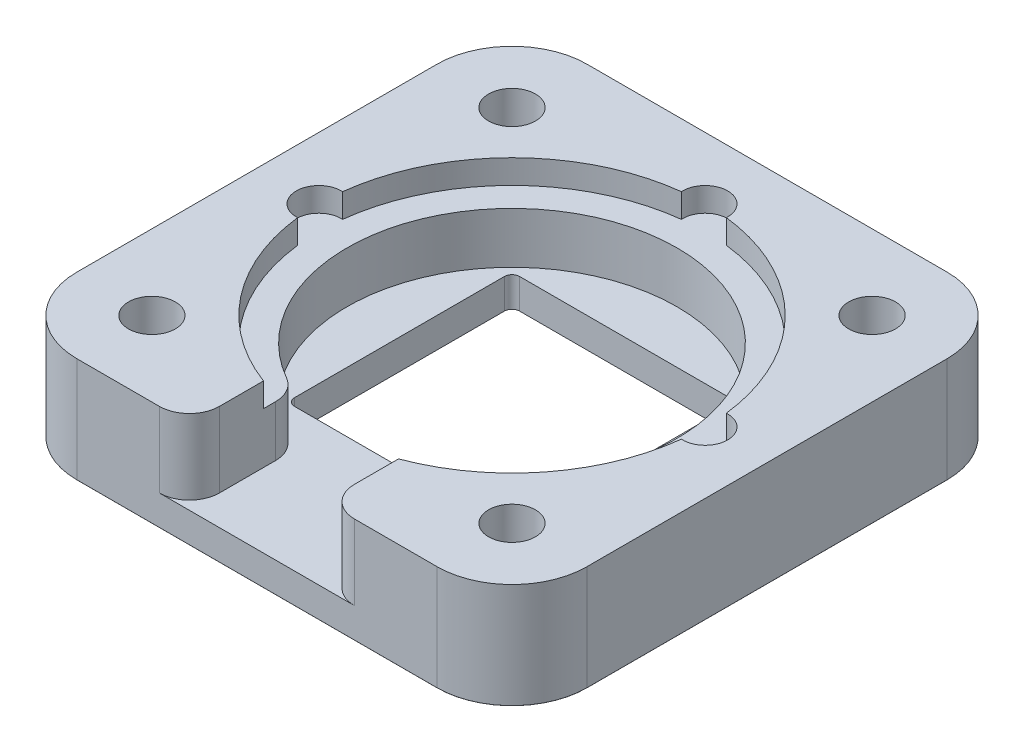
from build123d import *

# Parameters (mm, degrees)
SKETCH1_W           = 34
SKETCH1_H           = 34
BOSS_EXTRUDE1_DEPTH = 7
SKETCH2_R           = 11
CUT_EXTRUDE1_DEPTH  = 5
SKETCH3_R           = 1.5621
CUT_EXTRUDE2_DEPTH  = 8
SKETCH4_W           = 9
SKETCH4_H           = 12.899537492
CUT_EXTRUDE3_DEPTH  = 5
SKETCH5_R           = 2.6
CUT_EXTRUDE4_DEPTH  = 4
FILLET1_R           = 5
FILLET2_R           = 0.01
FILLET3_R           = 2
SKETCH6_W           = 15
SKETCH6_H           = 15
CUT_EXTRUDE5_DEPTH  = 2
FILLET6_R           = 0.5
SKETCH8_R           = 12.875
CUT_EXTRUDE6_DEPTH  = 1.6
SKETCH9_R           = 1.5
CUT_EXTRUDE7_DEPTH  = 1.6


with BuildPart() as part:
    # Sketch1 → Boss-Extrude1 (new body)
    with BuildSketch(Plane(origin=(0, 0, 0), x_dir=(1, 0, 0), z_dir=(0, 1, 0))):
        with Locations((-0.609342113, -3.800882142)):
            Rectangle(SKETCH1_W, SKETCH1_H)
    extrude(amount=BOSS_EXTRUDE1_DEPTH)

    # Sketch2 → Cut-Extrude1 (cut)
    with BuildSketch(Plane(origin=(0, 7, 0), x_dir=(1, 0, 0), z_dir=(0, 1, 0))):
        with Locations((-0.609342113, -3.800882142)):
            Circle(SKETCH2_R)
    extrude(amount=-CUT_EXTRUDE1_DEPTH, mode=Mode.SUBTRACT)

    # Sketch3 → Cut-Extrude2 (cut, through all)
    with BuildSketch(Plane(origin=(0, 7, 0), x_dir=(1, 0, 0), z_dir=(0, 1, 0))):
        with Locations((-12.609342113, 8.199117858)):
            Circle(SKETCH3_R)
        with Locations((-12.609342113, -15.800882142)):
            Circle(SKETCH3_R)
        with Locations((11.390657887, -15.800882142)):
            Circle(SKETCH3_R)
        with Locations((11.390657887, 8.199117858)):
            Circle(SKETCH3_R)
    extrude(amount=-CUT_EXTRUDE2_DEPTH, mode=Mode.SUBTRACT)

    # Sketch4 → Cut-Extrude3 (cut)
    with BuildSketch(Plane(origin=(0, 7, 0), x_dir=(1, 0, 0), z_dir=(0, 1, 0))):
        with Locations((-0.609342113, -16.792376967)):
            Rectangle(SKETCH4_W, SKETCH4_H)
    extrude(amount=-CUT_EXTRUDE3_DEPTH, mode=Mode.SUBTRACT)

    # Sketch5 → Cut-Extrude4 (cut)
    with BuildSketch(Plane.XZ):
        with Locations((-12.609342113, 15.800882142)):
            Circle(SKETCH5_R)
        with Locations((11.390657887, 15.800882142)):
            Circle(SKETCH5_R)
        with Locations((-12.609342113, -8.199117858)):
            Circle(SKETCH5_R)
        with Locations((11.390657887, -8.199117858)):
            Circle(SKETCH5_R)
    extrude(amount=-CUT_EXTRUDE4_DEPTH, mode=Mode.SUBTRACT)

    # Fillet1
    fillet1_edges = [part.edges().sort_by_distance(p)[0] for p in [
        (-17.609342113, 3.5, -13.199117858),
        (16.390657887, 3.5, -13.199117858),
        (16.390657887, 3.5, 20.800882142),
        (-17.609342113, 3.5, 20.800882142),
    ]]
    fillet(fillet1_edges, radius=FILLET1_R)

    # Fillet2
    fillet2_edges = [part.edges().sort_by_distance(p)[0] for p in [
        (-15.209342113, 0, 15.800882142),
        (8.790657887, 0, 15.800882142),
        (-15.209342113, 0, -8.199117858),
        (8.790657887, 0, -8.199117858),
        (16.390657887, 0, 3.800882142),
        (-17.609342113, 0, 3.800882142),
        (-0.609342113, 0, -13.199117858),
        (-0.609342113, 0, 20.800882142),
        (-16.144876019, 0, 19.336416048),
        (-16.144876019, 0, -11.734651764),
        (14.926191793, 0, -11.734651764),
        (14.926191793, 0, 19.336416048),
    ]]
    fillet(fillet2_edges, radius=FILLET2_R)

    # Fillet3
    fillet3_edges = [part.edges().sort_by_distance(p)[0] for p in [
        (-5.109342113, 4.5, 20.800882142),
        (-5.109342113, 4.5, 13.838312092),
        (3.890657887, 4.5, 20.800882142),
        (3.890657887, 4.5, 13.838312092),
    ]]
    fillet(fillet3_edges, radius=FILLET3_R)

    # Sketch6 → Cut-Extrude5 (cut)
    with BuildSketch(Plane.XZ):
        with Locations((-0.609342113, 3.800882142)):
            Rectangle(SKETCH6_W, SKETCH6_H)
    extrude(amount=-CUT_EXTRUDE5_DEPTH, mode=Mode.SUBTRACT)

    # Fillet6
    fillet6_edges = [part.edges().sort_by_distance(p)[0] for p in [
        (-8.109342113, 1, -3.699117858),
        (-8.109342113, 1, 11.300882142),
        (6.890657887, 1, 11.300882142),
        (6.890657887, 1, -3.699117858),
    ]]
    fillet(fillet6_edges, radius=FILLET6_R)

    # Sketch8 → Cut-Extrude6 (cut)
    with BuildSketch(Plane(origin=(0, 7, 0), x_dir=(1, 0, 0), z_dir=(0, 1, 0))):
        with Locations((-0.609342113, -3.800882142)):
            Circle(SKETCH8_R)
    extrude(amount=-CUT_EXTRUDE6_DEPTH, mode=Mode.SUBTRACT)

    # Sketch9 → Cut-Extrude7 (cut)
    with BuildSketch(Plane(origin=(0, 7, 0), x_dir=(1, 0, 0), z_dir=(0, 1, 0))):
        with Locations((-0.609342113, 9.074117858)):
            Circle(SKETCH9_R)
        with Locations((12.265657887, -3.800882142)):
            Circle(SKETCH9_R)
        with Locations((-13.484342113, -3.800882142)):
            Circle(SKETCH9_R)
    extrude(amount=-CUT_EXTRUDE7_DEPTH, mode=Mode.SUBTRACT)


solid = part.part
